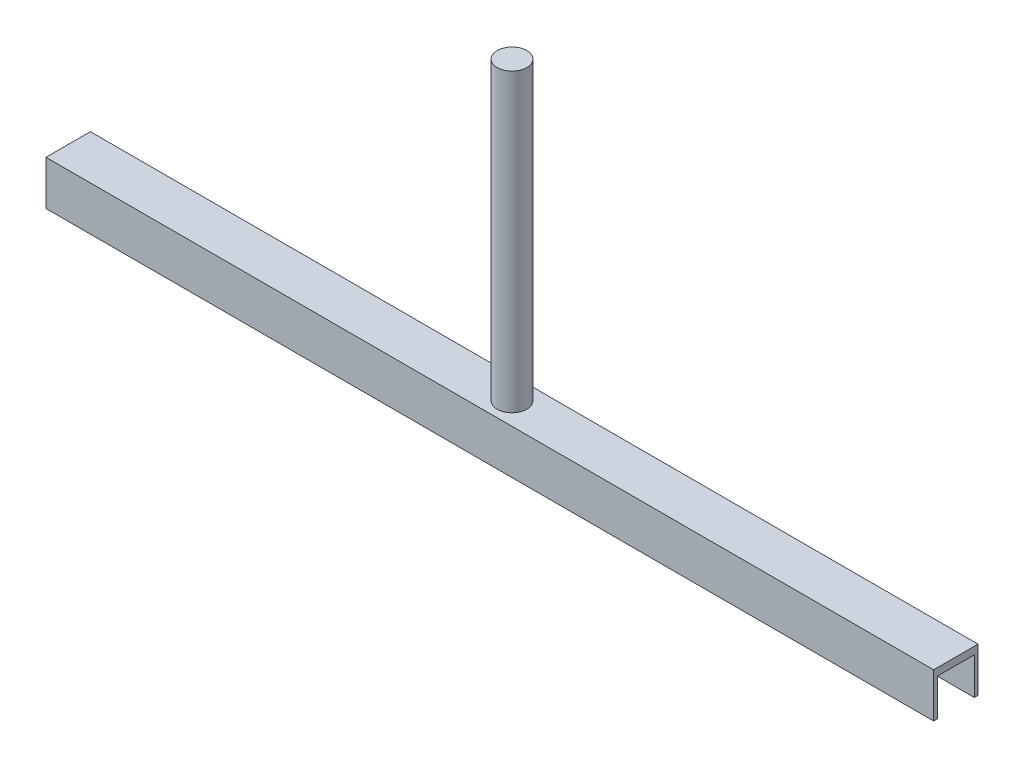
from build123d import *

# Parameters (mm, degrees)
SKETCH1_W           = 300
SKETCH1_H           = 15
BOSS_EXTRUDE1_DEPTH = 15
SKETCH2_W           = 300
SKETCH2_H           = 12.5
CUT_EXTRUDE2_DEPTH  = 12.5
SKETCH3_R           = 5
BOSS_EXTRUDE2_DEPTH = 100


with BuildPart() as part:
    # Sketch1 → Boss-Extrude1 (new body)
    with BuildSketch(Plane(origin=(0, 0, 0), x_dir=(1, 0, 0), z_dir=(0, 1, 0))):
        Rectangle(SKETCH1_W, SKETCH1_H)
    extrude(amount=BOSS_EXTRUDE1_DEPTH)

    # Sketch2 → Cut-Extrude2 (cut)
    with BuildSketch(Plane(origin=(0, 0, 0), x_dir=(1, 0, 0), z_dir=(0, 1, 0))):
        Rectangle(SKETCH2_W, SKETCH2_H)
    extrude(amount=CUT_EXTRUDE2_DEPTH, mode=Mode.SUBTRACT)

    # Sketch3 → Boss-Extrude2 (add)
    with BuildSketch(Plane(origin=(0, 15, 0), x_dir=(1, 0, 0), z_dir=(0, 1, 0))):
        Circle(SKETCH3_R)
    extrude(amount=BOSS_EXTRUDE2_DEPTH)


solid = part.part
